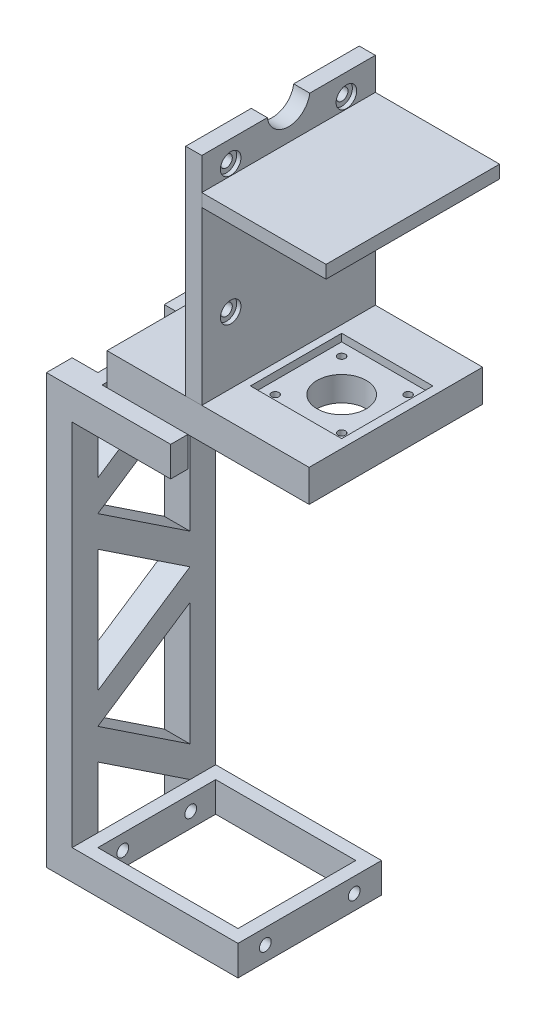
from build123d import *

# Parameters (mm, degrees)
SKETCH1_W            = 77.4
SKETCH1_H            = 67
SKETCH1_W_2          = 65.4
SKETCH1_H_2          = 55
BOSS_EXTRUDE1_DEPTH  = 14
SKETCH4_W            = 12
SKETCH4_H            = 12
BOSS_EXTRUDE2_DEPTH  = 200
SKETCH5_W            = 6
SKETCH5_H            = 67
BOSS_EXTRUDE3_DEPTH  = 14
BOSS_EXTRUDE4_DEPTH  = 12
SKETCH2_R            = 2.75
CUT_EXTRUDE1_DEPTH   = 6
SKETCH3_R            = 2.75
CUT_EXTRUDE2_DEPTH   = 6
SKETCH7_R            = 2.75
CUT_EXTRUDE3_DEPTH   = 223.441902527
SKETCH8_W            = 8
SKETCH8_H            = 14
BOSS_EXTRUDE5_DEPTH  = 40
SKETCH9_W            = 84.613001647
SKETCH9_H            = 81
SKETCH9_W_2          = 22.713460293
BOSS_EXTRUDE6_DEPTH  = 15
SKETCH10_W           = 42.6
SKETCH10_H           = 42.6
CUT_EXTRUDE4_DEPTH   = 3.5
SKETCH11_R           = 1.75
SKETCH11_R_2         = 11.5
CUT_EXTRUDE5_DEPTH   = 11.5
CUT_EXTRUDE6_START   = 8.5
SKETCH11_5_R         = 3
SKETCH11_5_R_2       = 1.75
SKETCH11_5_R_3       = 11.5
CUT_EXTRUDE6_DEPTH   = 3
SKETCH13_R           = 2.75
BOSS_EXTRUDE7_DEPTH  = 5.5
BOSS_EXTRUDE10_START = -5.5
SKETCH13_3_R         = 4.8
BOSS_EXTRUDE10_DEPTH = 2
SKETCH15_W           = 81
SKETCH15_H           = 6
BOSS_EXTRUDE9_DEPTH  = 58


with BuildPart() as part:
    # Sketch1 → Boss-Extrude1 (new body)
    with BuildSketch(Plane(origin=(0, 0, 0), x_dir=(1, 0, 0), z_dir=(0, 1, 0))):
        Rectangle(SKETCH1_W, SKETCH1_H)
        Rectangle(SKETCH1_W_2, SKETCH1_H_2, mode=Mode.SUBTRACT)
    extrude(amount=BOSS_EXTRUDE1_DEPTH)

    # Sketch4 → Boss-Extrude2 (add)
    with BuildSketch(Plane(origin=(0, 0, 0), x_dir=(1, 0, 0), z_dir=(0, 1, 0))):
        with Locations((-44.7, -27.5)):
            Rectangle(SKETCH4_W, SKETCH4_H)
        with Locations((-44.7, 27.5)):
            Rectangle(SKETCH4_W, SKETCH4_H)
    extrude(amount=BOSS_EXTRUDE2_DEPTH)

    # Sketch5 → Boss-Extrude3 (add)
    with BuildSketch(Plane(origin=(0, 200, 0), x_dir=(1, 0, 0), z_dir=(0, 1, 0))):
        with Locations((-35.7, 0)):
            Rectangle(SKETCH5_W, SKETCH5_H)
    extrude(amount=-BOSS_EXTRUDE3_DEPTH)

    # Sketch6 → Boss-Extrude4 (add)
    with BuildSketch(Plane.ZY.offset(50.7)):
        Polygon((21.5, 157.410301507), (-21.5, 186), (-21.5, 171.589698493), (21.5, 143), align=None)
        Polygon((21.5, 128.589698493), (21.5, 143), (-21.5, 114.410301507), (-21.5, 100), align=None)
        Polygon((21.5, 71.410301507), (-21.5, 100), (-21.5, 85.589698493), (21.5, 57), align=None)
        Polygon((21.5, 42.589698493), (21.5, 57), (-21.5, 28.410301507), (-21.5, 14), align=None)
    extrude(amount=-BOSS_EXTRUDE4_DEPTH)

    # Sketch2 → Cut-Extrude1 (cut)
    with BuildSketch(Plane(origin=(38.7, 0, 0), x_dir=(0, 0, -1), z_dir=(1, 0, 0))):
        with Locations((-20.75, 7)):
            Circle(SKETCH2_R)
        with Locations((20.75, 7)):
            Circle(SKETCH2_R)
    extrude(amount=-CUT_EXTRUDE1_DEPTH, mode=Mode.SUBTRACT)

    # Sketch3 → Cut-Extrude2 (cut)
    with BuildSketch(Plane(origin=(-32.7, 0, 0), x_dir=(0, 0, -1), z_dir=(1, 0, 0))):
        with Locations((15.85, 7)):
            Circle(SKETCH3_R)
        with Locations((-15.85, 7)):
            Circle(SKETCH3_R)
    extrude(amount=-CUT_EXTRUDE2_DEPTH, mode=Mode.SUBTRACT)

    # Sketch7 → Cut-Extrude3 (cut, through all)
    with BuildSketch(Plane(origin=(-32.7, 0, -32.7), x_dir=(0, 0, -1), z_dir=(1, 0, 0))):
        with Locations((-16.85, 193)):
            Circle(SKETCH7_R)
        with Locations((-48.55, 193)):
            Circle(SKETCH7_R)
    extrude(amount=-CUT_EXTRUDE3_DEPTH, mode=Mode.SUBTRACT)

    # Sketch8 → Boss-Extrude5 (add)
    with BuildSketch(Plane(origin=(-32.7, 0, 0), x_dir=(0, 0, -1), z_dir=(1, 0, 0))):
        with Locations((-29.5, 193)):
            Rectangle(SKETCH8_W, SKETCH8_H)
        with Locations((29.5, 193)):
            Rectangle(SKETCH8_W, SKETCH8_H)
    extrude(amount=BOSS_EXTRUDE5_DEPTH)


with BuildPart() as body_2:
    # Sketch9 → Boss-Extrude6 (new body)
    with BuildSketch(Plane(origin=(0, 215, 0), x_dir=(1, 0, 0), z_dir=(0, 1, 0))):
        with Locations((36.593499177, 0)):
            Rectangle(SKETCH9_W, SKETCH9_H)
        with Locations((-4.056730147, 0)):
            Rectangle(SKETCH9_W_2, SKETCH9_H)
    extrude(amount=BOSS_EXTRUDE6_DEPTH)

    # Sketch10 → Cut-Extrude4 (cut)
    with BuildSketch(Plane(origin=(0, 230, 0), x_dir=(1, 0, 0), z_dir=(0, 1, 0))):
        with Locations((53.6, 0)):
            Rectangle(SKETCH10_W, SKETCH10_H)
    extrude(amount=-CUT_EXTRUDE4_DEPTH, mode=Mode.SUBTRACT)

    # Sketch11 → Cut-Extrude5 (cut)
    with BuildSketch(Plane(origin=(0, 226.5, -221.5), x_dir=(1, 0, 0), z_dir=(0, -1, 0))):
        with Locations(Location((69.1, 237, 0), (0, 0, 90))):
            Circle(SKETCH11_R)
        with Locations(Location((38.1, 237, 0), (0, 0, 90))):
            Circle(SKETCH11_R)
        with Locations(Location((38.1, 206, 0), (0, 0, 90))):
            Circle(SKETCH11_R)
        with Locations(Location((69.1, 206, 0), (0, 0, 90))):
            Circle(SKETCH11_R)
        with Locations(Location((53.6, 221.5, 0), (0, 0, 90))):
            Circle(SKETCH11_R_2)
    extrude(amount=CUT_EXTRUDE5_DEPTH, mode=Mode.SUBTRACT)

    # Sketch11_5 → Cut-Extrude6 (cut)
    with BuildSketch(Plane(origin=(0, 226.5, -221.5), x_dir=(1, 0, 0), z_dir=(0, -1, 0)).offset(CUT_EXTRUDE6_START)):
        with Locations(Location((38.1, 237, 0), (0, 0, 90))):
            Circle(SKETCH11_5_R)
        with Locations(Location((38.1, 237, 0), (0, 0, 90))):
            Circle(SKETCH11_5_R_2, mode=Mode.SUBTRACT)
        with Locations(Location((69.1, 237, 0), (0, 0, 90))):
            Circle(SKETCH11_5_R)
        with Locations(Location((69.1, 237, 0), (0, 0, 90))):
            Circle(SKETCH11_5_R_2, mode=Mode.SUBTRACT)
        with Locations(Location((69.1, 206, 0), (0, 0, 90))):
            Circle(SKETCH11_5_R)
        with Locations(Location((69.1, 206, 0), (0, 0, 90))):
            Circle(SKETCH11_5_R_2, mode=Mode.SUBTRACT)
        with Locations(Location((38.1, 206, 0), (0, 0, 90))):
            Circle(SKETCH11_5_R)
        with Locations(Location((38.1, 206, 0), (0, 0, 90))):
            Circle(SKETCH11_5_R_2, mode=Mode.SUBTRACT)
        with Locations(Location((53.6, 221.5, 0), (0, 0, 90))):
            Circle(SKETCH11_5_R_3)
    extrude(amount=CUT_EXTRUDE6_DEPTH, mode=Mode.SUBTRACT)


with BuildPart() as body_3:
    # Sketch13 → Boss-Extrude7 (new body)
    with BuildSketch(Plane.ZY.offset(-21.3)):
        with BuildLine():
            Line((-9.905396324, 331), (-40.5, 331))
            Line((-40.5, 331), (-40.5, 230))
            Line((-40.5, 230), (40.5, 230))
            Line((40.5, 230), (40.5, 331))
            Line((40.5, 331), (9.905396324, 331))
            ThreePointArc((9.905396324, 331), (0, 322.372269531), (-9.905396324, 331))
        make_face()
        with Locations((-27, 261)):
            Circle(SKETCH13_R, mode=Mode.SUBTRACT)
        with Locations((27, 321)):
            Circle(SKETCH13_R, mode=Mode.SUBTRACT)
        with Locations((27, 261)):
            Circle(SKETCH13_R, mode=Mode.SUBTRACT)
        with Locations((-27, 321)):
            Circle(SKETCH13_R, mode=Mode.SUBTRACT)
    extrude(amount=-BOSS_EXTRUDE7_DEPTH)

    # Sketch13_3 → Boss-Extrude10 (add)
    with BuildSketch(Plane.ZY.offset(-21.3).offset(BOSS_EXTRUDE10_START)):
        with BuildLine():
            Line((-9.905396324, 331), (-40.5, 331))
            Line((-40.5, 331), (-40.5, 230))
            Line((-40.5, 230), (40.5, 230))
            Line((40.5, 230), (40.5, 331))
            Line((40.5, 331), (9.905396324, 331))
            ThreePointArc((9.905396324, 331), (0, 322.372269531), (-9.905396324, 331))
        make_face()
        with Locations((-27, 261)):
            Circle(SKETCH13_3_R, mode=Mode.SUBTRACT)
        with Locations((27, 261)):
            Circle(SKETCH13_3_R, mode=Mode.SUBTRACT)
        with Locations((-27, 321)):
            Circle(SKETCH13_3_R, mode=Mode.SUBTRACT)
        with Locations((27, 321)):
            Circle(SKETCH13_3_R, mode=Mode.SUBTRACT)
    extrude(amount=-BOSS_EXTRUDE10_DEPTH)


with BuildPart() as body_4:
    # Sketch15 → Boss-Extrude9 (new body)
    with BuildSketch(Plane(origin=(28.8, 0, 0), x_dir=(0, 0, -1), z_dir=(1, 0, 0))):
        with Locations((0, 313)):
            Rectangle(SKETCH15_W, SKETCH15_H)
    extrude(amount=BOSS_EXTRUDE9_DEPTH)


solid = Compound([part.part, body_2.part, body_3.part, body_4.part])
